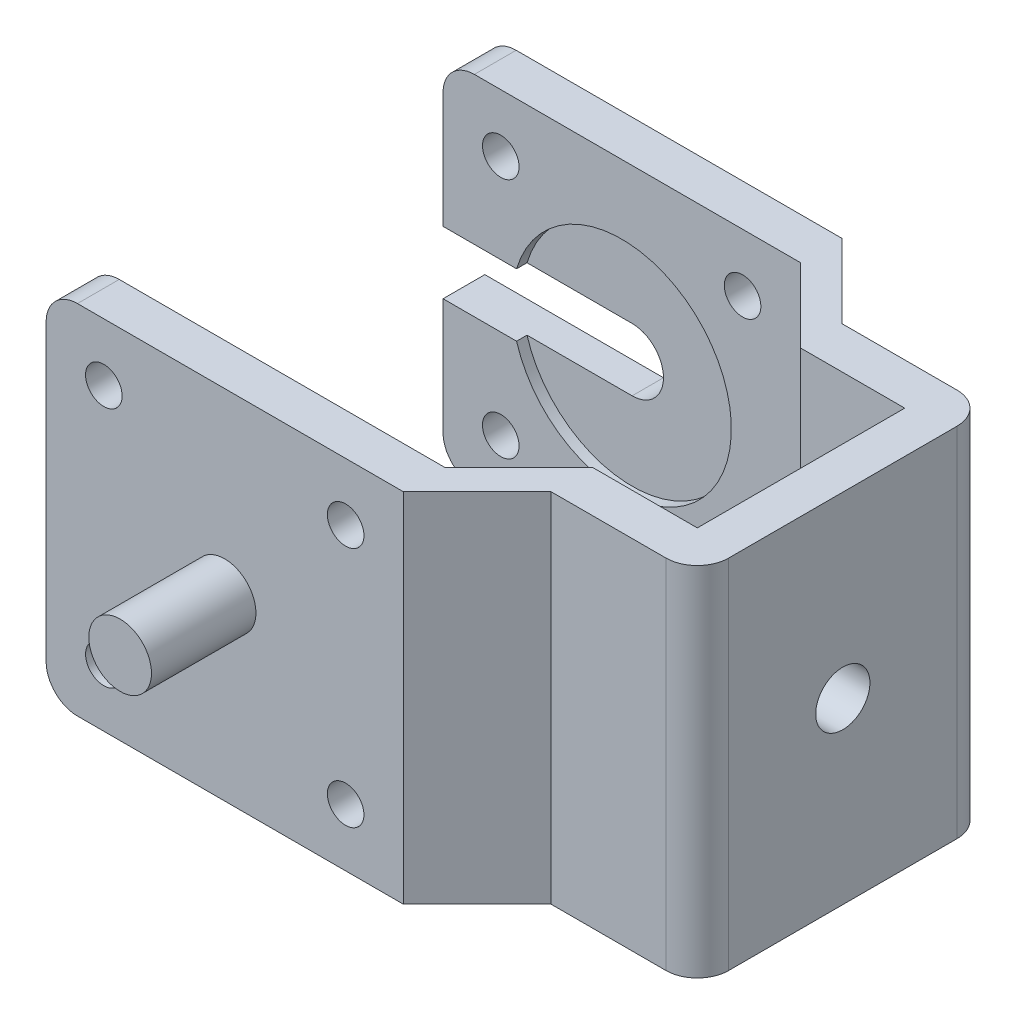
from build123d import *

# Parameters (mm, degrees)
BOSS_EXTRUDE1_DEPTH = 34.2
SKETCH2_R           = 1.75
SKETCH2_R_2         = 3
CUT_EXTRUDE2_DEPTH  = 4
SKETCH3_R           = 10.5
CUT_EXTRUDE3_DEPTH  = 1
SKETCH5_R           = 1.75
CUT_EXTRUDE7_DEPTH  = 4
FILLET2_R           = 3
FILLET3_R           = 3
SKETCH12_R          = 2.595
CUT_EXTRUDE8_DEPTH  = 4
SKETCH14_W          = 17.1
SKETCH14_H          = 6
CUT_EXTRUDE9_DEPTH  = 4
SKETCH15_R          = 3
BOSS_EXTRUDE2_DEPTH = 10


with BuildPart() as part:
    # Sketch1 → Boss-Extrude1 (new body)
    with BuildSketch(Plane(origin=(0, 0, 0), x_dir=(1, 0, 0), z_dir=(0, 1, 0))):
        Polygon((0, 0), (34.2, 0), (41.271067812, -7.071067812), (51.271067812, -7.071067812), (51.271067812, -26.928932188), (41.271067812, -26.928932188), (34.2, -34), (0, -34), (0, -38), (34.2, -38), (41.271067812, -30.928932188), (55.271067812, -30.928932188), (55.271067812, -26.928932188), (55.271067812, -3.071067812), (51.271067812, -3.071067812), (41.271067812, -3.071067812), (34.2, 4), (0, 4), align=None)
    extrude(amount=BOSS_EXTRUDE1_DEPTH)

    # Sketch2 → Cut-Extrude2 (cut)
    with BuildSketch(Plane(origin=(0, 0, -4), x_dir=(-1, 0, 0), z_dir=(0, 0, -1))):
        with Locations((-28.675, 28.675)):
            Circle(SKETCH2_R)
        with Locations((-5.525, 28.675)):
            Circle(SKETCH2_R)
        with Locations((-5.525, 5.525)):
            Circle(SKETCH2_R)
        with Locations((-28.675, 5.525)):
            Circle(SKETCH2_R)
        with Locations((-17.1, 17.1)):
            Circle(SKETCH2_R_2)
    extrude(amount=-CUT_EXTRUDE2_DEPTH, mode=Mode.SUBTRACT)

    # Sketch3 → Cut-Extrude3 (cut)
    with BuildSketch(Plane.XY):
        with Locations((17.1, 17.1)):
            Circle(SKETCH3_R)
    extrude(amount=-CUT_EXTRUDE3_DEPTH, mode=Mode.SUBTRACT)

    # Sketch5 → Cut-Extrude7 (cut)
    with BuildSketch(Plane.XY.offset(38)):
        with Locations((28.675, 28.675)):
            Circle(SKETCH5_R)
        with Locations((5.525, 28.675)):
            Circle(SKETCH5_R)
        with Locations((5.525, 5.525)):
            Circle(SKETCH5_R)
        with Locations((28.675, 5.525)):
            Circle(SKETCH5_R)
    extrude(amount=-CUT_EXTRUDE7_DEPTH, mode=Mode.SUBTRACT)

    # Fillet2
    fillet2_edges = [part.edges().sort_by_distance(p)[0] for p in [
        (0, 0, 36),
        (0, 0, -2),
        (0, 34.2, 36),
        (0, 34.2, -2),
    ]]
    fillet(fillet2_edges, radius=FILLET2_R)

    # Fillet3
    fillet3_edges = [part.edges().sort_by_distance(p)[0] for p in [
        (55.271067812, 17.1, 3.071067812),
        (55.271067812, 17.1, 30.928932188),
    ]]
    fillet(fillet3_edges, radius=FILLET3_R)

    # Sketch12 → Cut-Extrude8 (cut)
    with BuildSketch(Plane(origin=(55.271067812, 0, 0), x_dir=(0, 0, -1), z_dir=(1, 0, 0))):
        with Locations((-17, 17.1)):
            Circle(SKETCH12_R)
    extrude(amount=-CUT_EXTRUDE8_DEPTH, mode=Mode.SUBTRACT)

    # Sketch14 → Cut-Extrude9 (cut)
    with BuildSketch(Plane(origin=(0, 0, -4), x_dir=(-1, 0, 0), z_dir=(0, 0, -1))):
        with Locations((-8.55, 17.1)):
            Rectangle(SKETCH14_W, SKETCH14_H)
    extrude(amount=-CUT_EXTRUDE9_DEPTH, mode=Mode.SUBTRACT)

    # Sketch15 → Boss-Extrude2 (add)
    with BuildSketch(Plane.XY.offset(38)):
        with Locations((17.086482483, 17.08469774)):
            Circle(SKETCH15_R)
    extrude(amount=BOSS_EXTRUDE2_DEPTH)


solid = part.part
